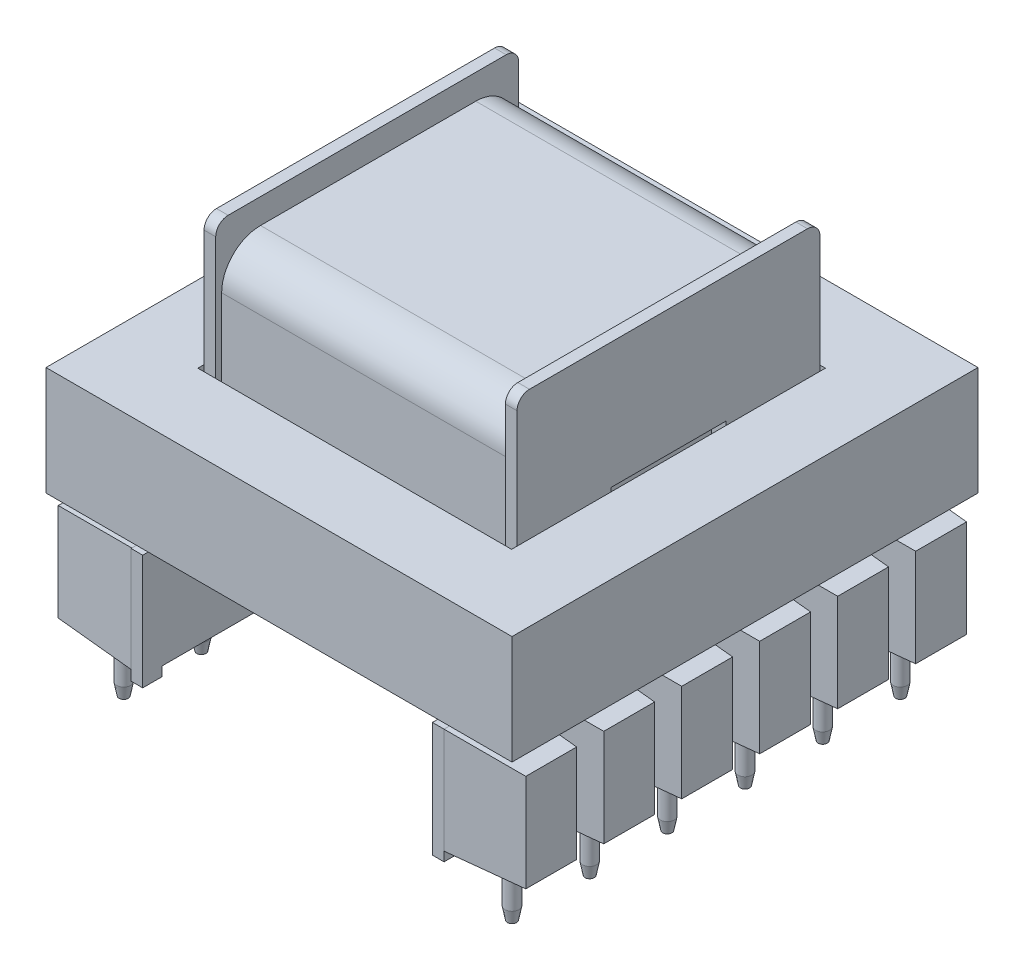
from build123d import *

# Parameters (mm, degrees)
BOSS_EXTRUDE1_DEPTH           = 11.8
BOSS_EXTRUDE1_DEPTH_BACK      = 11.8
SKETCH3_W                     = 18.65
SKETCH3_H                     = 7.4
CUT_EXTRUDE1_DEPTH            = 11.8
SKETCH4_W                     = 7.4
SKETCH4_H                     = 7.4
CUT_EXTRUDE2_DEPTH            = 25
FILLET1_R                     = 0.8
BOSS_EXTRUDE2_DEPTH           = 4.7
BOSS_EXTRUDE2_DEPTH_BACK      = 24.2
SKETCH5_W                     = 0.75
SKETCH5_H                     = 7.4
SKETCH6_W                     = 26.4
SKETCH6_H                     = 0.6
CUT_EXTRUDE3_DEPTH            = 25.3
SKETCH7_W                     = 3.8
SKETCH7_H                     = 6.8
BOSS_EXTRUDE3_DEPTH           = 5
BOSS_EXTRUDE3_DRAFT           = 3
BOSS_EXTRUDE3_PROFILE_2_DEPTH = 5
BOSS_EXTRUDE3_PROFILE_2_DRAFT = 3
BOSS_EXTRUDE3_PROFILE_3_DEPTH = 5
BOSS_EXTRUDE3_PROFILE_3_DRAFT = 3
BOSS_EXTRUDE3_PROFILE_4_DEPTH = 5
BOSS_EXTRUDE3_PROFILE_4_DRAFT = 3
BOSS_EXTRUDE3_PROFILE_5_DEPTH = 5
BOSS_EXTRUDE3_PROFILE_5_DRAFT = 3
BOSS_EXTRUDE3_PROFILE_6_DEPTH = 5
BOSS_EXTRUDE3_PROFILE_6_DRAFT = 3
SKETCH8_W                     = 3.8
SKETCH8_H                     = 6.8
BOSS_EXTRUDE4_DEPTH           = 5
BOSS_EXTRUDE4_DRAFT           = -3
BOSS_EXTRUDE4_PROFILE_2_DEPTH = 5
BOSS_EXTRUDE4_PROFILE_2_DRAFT = -3
BOSS_EXTRUDE4_PROFILE_3_DEPTH = 5
BOSS_EXTRUDE4_PROFILE_3_DRAFT = -3
BOSS_EXTRUDE4_PROFILE_4_DEPTH = 5
BOSS_EXTRUDE4_PROFILE_4_DRAFT = -3
BOSS_EXTRUDE4_PROFILE_5_DEPTH = 5
BOSS_EXTRUDE4_PROFILE_5_DRAFT = -3
BOSS_EXTRUDE4_PROFILE_6_DEPTH = 5
BOSS_EXTRUDE4_PROFILE_6_DRAFT = -3
SKETCH9_R                     = 0.45
BOSS_EXTRUDE5_DEPTH           = 4
BOSS_EXTRUDE5_OTHER_WAY_DEPTH = 0.8
BOSS_EXTRUDE5_OTHER_WAY_TAPER = 11
BOSS_EXTRUDE6_DEPTH           = 3.5
BOSS_EXTRUDE6_DEPTH_BACK      = 3.5
SKETCH12_W                    = 30
SKETCH12_H                    = 30
SKETCH12_W_2                  = 20.2
SKETCH12_H_2                  = 20.2
BOSS_EXTRUDE7_DEPTH           = 9.7
BOSS_EXTRUDE7_DEPTH_BACK      = 8.7
SKETCH13_W                    = 18.86
SKETCH13_H                    = 20.502794882
FILLET3_R                     = 2.5


with BuildPart() as part:
    # Sketch2 → Boss-Extrude1 (new, two sides: drawn at the far end of the back side and taken through both)
    with BuildSketch(Plane(origin=(0, 0, 0), x_dir=(1, 0, 0), z_dir=(0, 1, 0)).offset(-BOSS_EXTRUDE1_DEPTH_BACK)):
        Polygon((-9.514148802, 9.75), (-9.514148802, -9.75), (-8.764148802, -9.75), (-8.764148802, -4.35), (9.885851198, -4.35), (9.885851198, -9.75), (10.635851198, -9.75), (10.635851198, 9.75), (9.885851198, 9.75), (9.885851198, 4.35), (-8.764148802, 4.35), (-8.764148802, 9.75), align=None)
    extrude(amount=BOSS_EXTRUDE1_DEPTH + BOSS_EXTRUDE1_DEPTH_BACK)

    # Sketch3 → Cut-Extrude1 (cut)
    with BuildSketch(Plane.XY.offset(4.35)):
        with Locations((0.560851198, 8.1)):
            Rectangle(SKETCH3_W, SKETCH3_H)
        with Locations((0.560851198, -8.1)):
            Rectangle(SKETCH3_W, SKETCH3_H)
    extrude(amount=-CUT_EXTRUDE1_DEPTH, mode=Mode.SUBTRACT)

    # Sketch4 → Cut-Extrude2 (cut)
    with BuildSketch(Plane(origin=(10.635851198, 0, 0), x_dir=(0, 0, -1), z_dir=(1, 0, 0))):
        Rectangle(SKETCH4_W, SKETCH4_H)
    extrude(amount=-CUT_EXTRUDE2_DEPTH, mode=Mode.SUBTRACT)

    # Fillet1
    fillet1_edges = [part.edges().sort_by_distance(p)[0] for p in [
        (0.560851198, 4.4, -4.35),
        (0.560851198, -4.4, -4.35),
        (0.560851198, 4.4, 4.35),
        (0.560851198, -4.4, 4.35),
        (-9.139148802, 11.8, -9.75),
        (10.260851198, 11.8, -9.75),
        (-9.139148802, 11.8, 9.75),
        (10.260851198, 11.8, 9.75),
    ]]
    fillet(fillet1_edges, radius=FILLET1_R)

    # Sketch5 → Boss-Extrude2 (add, two sides: drawn at the far end of the back side and taken through both)
    with BuildSketch(Plane.XY.offset(9.75).offset(-BOSS_EXTRUDE2_DEPTH_BACK)):
        with Locations((10.260851198, -8.1)):
            Rectangle(SKETCH5_W, SKETCH5_H)
        with Locations((-9.139148802, -8.1)):
            Rectangle(SKETCH5_W, SKETCH5_H)
    extrude(amount=BOSS_EXTRUDE2_DEPTH + BOSS_EXTRUDE2_DEPTH_BACK)

    # Sketch6 → Cut-Extrude3 (cut)
    with BuildSketch(Plane.ZY.offset(9.514148802)):
        with Locations((0, -11.5)):
            Rectangle(SKETCH6_W, SKETCH6_H)
    extrude(amount=-CUT_EXTRUDE3_DEPTH, mode=Mode.SUBTRACT)


with BuildPart() as boss_extrude3_tool:
    # Sketch7 → Boss-Extrude3 (with draft: the straight prism first)
    with BuildSketch(Plane.ZY.offset(9.514148802)):
        with Locations((-12.5, -7.8)):
            Rectangle(SKETCH7_W, SKETCH7_H)
    extrude(amount=BOSS_EXTRUDE3_DEPTH)
    # Boss-Extrude3: the draft: its side faces are tilted about the plane it starts from
    boss_extrude3_sides = [boss_extrude3_tool.faces().sort_by_distance(p)[0] for p in [
        (-12.014148802, -4.4, -12.5),
        (-12.014148802, -7.8, -14.4),
        (-12.014148802, -11.2, -12.5),
        (-12.014148802, -7.8, -10.6),
    ]]
    draft(boss_extrude3_sides, Plane.ZY.offset(9.514148802), BOSS_EXTRUDE3_DRAFT)


with BuildPart() as part_1:
    add(part.part)

    # Boss-Extrude3: add boss_extrude3_tool
    add(boss_extrude3_tool.part)


with BuildPart() as boss_extrude3_profile_2_tool:
    # Sketch7 → Boss-Extrude3 profile 2 (with draft: the straight prism first)
    with BuildSketch(Plane.ZY.offset(9.514148802)):
        with Locations((-7.5, -7.8)):
            Rectangle(SKETCH7_W, SKETCH7_H)
    extrude(amount=BOSS_EXTRUDE3_PROFILE_2_DEPTH)
    # Boss-Extrude3 profile 2: the draft: its side faces are tilted about the plane it starts from
    boss_extrude3_profile_2_sides = [boss_extrude3_profile_2_tool.faces().sort_by_distance(p)[0] for p in [
        (-12.014148802, -7.8, -9.4),
        (-12.014148802, -11.2, -7.5),
        (-12.014148802, -7.8, -5.6),
        (-12.014148802, -4.4, -7.5),
    ]]
    draft(boss_extrude3_profile_2_sides, Plane.ZY.offset(9.514148802), BOSS_EXTRUDE3_PROFILE_2_DRAFT)


with BuildPart() as part_2:
    add(part_1.part)

    # Boss-Extrude3 profile 2: add boss_extrude3_profile_2_tool
    add(boss_extrude3_profile_2_tool.part)


with BuildPart() as boss_extrude3_profile_3_tool:
    # Sketch7 → Boss-Extrude3 profile 3 (with draft: the straight prism first)
    with BuildSketch(Plane.ZY.offset(9.514148802)):
        with Locations((-2.5, -7.8)):
            Rectangle(SKETCH7_W, SKETCH7_H)
    extrude(amount=BOSS_EXTRUDE3_PROFILE_3_DEPTH)
    # Boss-Extrude3 profile 3: the draft: its side faces are tilted about the plane it starts from
    boss_extrude3_profile_3_sides = [boss_extrude3_profile_3_tool.faces().sort_by_distance(p)[0] for p in [
        (-12.014148802, -7.8, -4.4),
        (-12.014148802, -11.2, -2.5),
        (-12.014148802, -7.8, -0.6),
        (-12.014148802, -4.4, -2.5),
    ]]
    draft(boss_extrude3_profile_3_sides, Plane.ZY.offset(9.514148802), BOSS_EXTRUDE3_PROFILE_3_DRAFT)


with BuildPart() as part_3:
    add(part_2.part)

    # Boss-Extrude3 profile 3: add boss_extrude3_profile_3_tool
    add(boss_extrude3_profile_3_tool.part)


with BuildPart() as boss_extrude3_profile_4_tool:
    # Sketch7 → Boss-Extrude3 profile 4 (with draft: the straight prism first)
    with BuildSketch(Plane.ZY.offset(9.514148802)):
        with Locations((2.5, -7.8)):
            Rectangle(SKETCH7_W, SKETCH7_H)
    extrude(amount=BOSS_EXTRUDE3_PROFILE_4_DEPTH)
    # Boss-Extrude3 profile 4: the draft: its side faces are tilted about the plane it starts from
    boss_extrude3_profile_4_sides = [boss_extrude3_profile_4_tool.faces().sort_by_distance(p)[0] for p in [
        (-12.014148802, -7.8, 0.6),
        (-12.014148802, -11.2, 2.5),
        (-12.014148802, -7.8, 4.4),
        (-12.014148802, -4.4, 2.5),
    ]]
    draft(boss_extrude3_profile_4_sides, Plane.ZY.offset(9.514148802), BOSS_EXTRUDE3_PROFILE_4_DRAFT)


with BuildPart() as part_4:
    add(part_3.part)

    # Boss-Extrude3 profile 4: add boss_extrude3_profile_4_tool
    add(boss_extrude3_profile_4_tool.part)


with BuildPart() as boss_extrude3_profile_5_tool:
    # Sketch7 → Boss-Extrude3 profile 5 (with draft: the straight prism first)
    with BuildSketch(Plane.ZY.offset(9.514148802)):
        with Locations((7.5, -7.8)):
            Rectangle(SKETCH7_W, SKETCH7_H)
    extrude(amount=BOSS_EXTRUDE3_PROFILE_5_DEPTH)
    # Boss-Extrude3 profile 5: the draft: its side faces are tilted about the plane it starts from
    boss_extrude3_profile_5_sides = [boss_extrude3_profile_5_tool.faces().sort_by_distance(p)[0] for p in [
        (-12.014148802, -7.8, 5.6),
        (-12.014148802, -11.2, 7.5),
        (-12.014148802, -7.8, 9.4),
        (-12.014148802, -4.4, 7.5),
    ]]
    draft(boss_extrude3_profile_5_sides, Plane.ZY.offset(9.514148802), BOSS_EXTRUDE3_PROFILE_5_DRAFT)


with BuildPart() as part_5:
    add(part_4.part)

    # Boss-Extrude3 profile 5: add boss_extrude3_profile_5_tool
    add(boss_extrude3_profile_5_tool.part)


with BuildPart() as boss_extrude3_profile_6_tool:
    # Sketch7 → Boss-Extrude3 profile 6 (with draft: the straight prism first)
    with BuildSketch(Plane.ZY.offset(9.514148802)):
        with Locations((12.5, -7.8)):
            Rectangle(SKETCH7_W, SKETCH7_H)
    extrude(amount=BOSS_EXTRUDE3_PROFILE_6_DEPTH)
    # Boss-Extrude3 profile 6: the draft: its side faces are tilted about the plane it starts from
    boss_extrude3_profile_6_sides = [boss_extrude3_profile_6_tool.faces().sort_by_distance(p)[0] for p in [
        (-12.014148802, -7.8, 10.6),
        (-12.014148802, -11.2, 12.5),
        (-12.014148802, -7.8, 14.4),
        (-12.014148802, -4.4, 12.5),
    ]]
    draft(boss_extrude3_profile_6_sides, Plane.ZY.offset(9.514148802), BOSS_EXTRUDE3_PROFILE_6_DRAFT)


with BuildPart() as part_6:
    add(part_5.part)

    # Boss-Extrude3 profile 6: add boss_extrude3_profile_6_tool
    add(boss_extrude3_profile_6_tool.part)


with BuildPart() as boss_extrude4_tool:
    # Sketch8 → Boss-Extrude4 (with draft: the straight prism first)
    with BuildSketch(Plane(origin=(10.635851198, 0, -10.635851198), x_dir=(0, 0, 1), z_dir=(-1, 0, 0))):
        with Locations((-1.914148802, -7.8)):
            Rectangle(SKETCH8_W, SKETCH8_H)
    extrude(amount=-BOSS_EXTRUDE4_DEPTH)
    # Boss-Extrude4: the draft: its side faces are tilted about the plane it starts from
    boss_extrude4_sides = [boss_extrude4_tool.faces().sort_by_distance(p)[0] for p in [
        (13.135851198, -7.8, -14.45),
        (13.135851198, -11.2, -12.55),
        (13.135851198, -7.8, -10.65),
        (13.135851198, -4.4, -12.55),
    ]]
    draft(boss_extrude4_sides, Plane(origin=(10.635851198, 0, -10.635851198), x_dir=(0, 0, 1), z_dir=(-1, 0, 0)), BOSS_EXTRUDE4_DRAFT)


with BuildPart() as part_7:
    add(part_6.part)

    # Boss-Extrude4: add boss_extrude4_tool
    add(boss_extrude4_tool.part)


with BuildPart() as boss_extrude4_profile_2_tool:
    # Sketch8 → Boss-Extrude4 profile 2 (with draft: the straight prism first)
    with BuildSketch(Plane(origin=(10.635851198, 0, -10.635851198), x_dir=(0, 0, 1), z_dir=(-1, 0, 0))):
        with Locations((3.105851198, -7.8)):
            Rectangle(SKETCH8_W, SKETCH8_H)
    extrude(amount=-BOSS_EXTRUDE4_PROFILE_2_DEPTH)
    # Boss-Extrude4 profile 2: the draft: its side faces are tilted about the plane it starts from
    boss_extrude4_profile_2_sides = [boss_extrude4_profile_2_tool.faces().sort_by_distance(p)[0] for p in [
        (13.135851198, -7.8, -9.43),
        (13.135851198, -11.2, -7.53),
        (13.135851198, -7.8, -5.63),
        (13.135851198, -4.4, -7.53),
    ]]
    draft(boss_extrude4_profile_2_sides, Plane(origin=(10.635851198, 0, -10.635851198), x_dir=(0, 0, 1), z_dir=(-1, 0, 0)), BOSS_EXTRUDE4_PROFILE_2_DRAFT)


with BuildPart() as part_8:
    add(part_7.part)

    # Boss-Extrude4 profile 2: add boss_extrude4_profile_2_tool
    add(boss_extrude4_profile_2_tool.part)


with BuildPart() as boss_extrude4_profile_3_tool:
    # Sketch8 → Boss-Extrude4 profile 3 (with draft: the straight prism first)
    with BuildSketch(Plane(origin=(10.635851198, 0, -10.635851198), x_dir=(0, 0, 1), z_dir=(-1, 0, 0))):
        with Locations((8.125851198, -7.8)):
            Rectangle(SKETCH8_W, SKETCH8_H)
    extrude(amount=-BOSS_EXTRUDE4_PROFILE_3_DEPTH)
    # Boss-Extrude4 profile 3: the draft: its side faces are tilted about the plane it starts from
    boss_extrude4_profile_3_sides = [boss_extrude4_profile_3_tool.faces().sort_by_distance(p)[0] for p in [
        (13.135851198, -7.8, -4.41),
        (13.135851198, -11.2, -2.51),
        (13.135851198, -7.8, -0.61),
        (13.135851198, -4.4, -2.51),
    ]]
    draft(boss_extrude4_profile_3_sides, Plane(origin=(10.635851198, 0, -10.635851198), x_dir=(0, 0, 1), z_dir=(-1, 0, 0)), BOSS_EXTRUDE4_PROFILE_3_DRAFT)


with BuildPart() as part_9:
    add(part_8.part)

    # Boss-Extrude4 profile 3: add boss_extrude4_profile_3_tool
    add(boss_extrude4_profile_3_tool.part)


with BuildPart() as boss_extrude4_profile_4_tool:
    # Sketch8 → Boss-Extrude4 profile 4 (with draft: the straight prism first)
    with BuildSketch(Plane(origin=(10.635851198, 0, -10.635851198), x_dir=(0, 0, 1), z_dir=(-1, 0, 0))):
        with Locations((13.145851198, -7.8)):
            Rectangle(SKETCH8_W, SKETCH8_H)
    extrude(amount=-BOSS_EXTRUDE4_PROFILE_4_DEPTH)
    # Boss-Extrude4 profile 4: the draft: its side faces are tilted about the plane it starts from
    boss_extrude4_profile_4_sides = [boss_extrude4_profile_4_tool.faces().sort_by_distance(p)[0] for p in [
        (13.135851198, -7.8, 0.61),
        (13.135851198, -11.2, 2.51),
        (13.135851198, -7.8, 4.41),
        (13.135851198, -4.4, 2.51),
    ]]
    draft(boss_extrude4_profile_4_sides, Plane(origin=(10.635851198, 0, -10.635851198), x_dir=(0, 0, 1), z_dir=(-1, 0, 0)), BOSS_EXTRUDE4_PROFILE_4_DRAFT)


with BuildPart() as part_10:
    add(part_9.part)

    # Boss-Extrude4 profile 4: add boss_extrude4_profile_4_tool
    add(boss_extrude4_profile_4_tool.part)


with BuildPart() as boss_extrude4_profile_5_tool:
    # Sketch8 → Boss-Extrude4 profile 5 (with draft: the straight prism first)
    with BuildSketch(Plane(origin=(10.635851198, 0, -10.635851198), x_dir=(0, 0, 1), z_dir=(-1, 0, 0))):
        with Locations((18.165851198, -7.8)):
            Rectangle(SKETCH8_W, SKETCH8_H)
    extrude(amount=-BOSS_EXTRUDE4_PROFILE_5_DEPTH)
    # Boss-Extrude4 profile 5: the draft: its side faces are tilted about the plane it starts from
    boss_extrude4_profile_5_sides = [boss_extrude4_profile_5_tool.faces().sort_by_distance(p)[0] for p in [
        (13.135851198, -7.8, 5.63),
        (13.135851198, -11.2, 7.53),
        (13.135851198, -7.8, 9.43),
        (13.135851198, -4.4, 7.53),
    ]]
    draft(boss_extrude4_profile_5_sides, Plane(origin=(10.635851198, 0, -10.635851198), x_dir=(0, 0, 1), z_dir=(-1, 0, 0)), BOSS_EXTRUDE4_PROFILE_5_DRAFT)


with BuildPart() as part_11:
    add(part_10.part)

    # Boss-Extrude4 profile 5: add boss_extrude4_profile_5_tool
    add(boss_extrude4_profile_5_tool.part)


with BuildPart() as boss_extrude4_profile_6_tool:
    # Sketch8 → Boss-Extrude4 profile 6 (with draft: the straight prism first)
    with BuildSketch(Plane(origin=(10.635851198, 0, -10.635851198), x_dir=(0, 0, 1), z_dir=(-1, 0, 0))):
        with Locations((23.185851198, -7.8)):
            Rectangle(SKETCH8_W, SKETCH8_H)
    extrude(amount=-BOSS_EXTRUDE4_PROFILE_6_DEPTH)
    # Boss-Extrude4 profile 6: the draft: its side faces are tilted about the plane it starts from
    boss_extrude4_profile_6_sides = [boss_extrude4_profile_6_tool.faces().sort_by_distance(p)[0] for p in [
        (13.135851198, -4.4, 12.55),
        (13.135851198, -7.8, 10.65),
        (13.135851198, -11.2, 12.55),
        (13.135851198, -7.8, 14.45),
    ]]
    draft(boss_extrude4_profile_6_sides, Plane(origin=(10.635851198, 0, -10.635851198), x_dir=(0, 0, 1), z_dir=(-1, 0, 0)), BOSS_EXTRUDE4_PROFILE_6_DRAFT)


with BuildPart() as part_12:
    add(part_11.part)

    # Boss-Extrude4 profile 6: add boss_extrude4_profile_6_tool
    add(boss_extrude4_profile_6_tool.part)

    # Sketch9 → Boss-Extrude5 (add)
    with BuildSketch(Plane(origin=(0, -14, 0), x_dir=(1, 0, 0), z_dir=(0, 1, 0))):
        with Locations((-11.939148802, 12.5)):
            Circle(SKETCH9_R)
        with Locations((-11.939148802, 7.5)):
            Circle(SKETCH9_R)
        with Locations((-11.939148802, 2.5)):
            Circle(SKETCH9_R)
        with Locations((-11.939148802, -2.5)):
            Circle(SKETCH9_R)
        with Locations((-11.939148802, -7.5)):
            Circle(SKETCH9_R)
        with Locations((-11.939148802, -12.5)):
            Circle(SKETCH9_R)
        with Locations((13.060851198, -12.5)):
            Circle(SKETCH9_R)
        with Locations((13.060851198, -7.5)):
            Circle(SKETCH9_R)
        with Locations((13.060851198, -2.5)):
            Circle(SKETCH9_R)
        with Locations((13.060851198, 2.5)):
            Circle(SKETCH9_R)
        with Locations((13.060851198, 7.5)):
            Circle(SKETCH9_R)
        with Locations((13.060851198, 12.5)):
            Circle(SKETCH9_R)
    extrude(amount=BOSS_EXTRUDE5_DEPTH)

    # Sketch9 → Boss-Extrude5 other way (add)
    with BuildSketch(Plane(origin=(0, -14, 0), x_dir=(1, 0, 0), z_dir=(0, 1, 0))):
        with Locations((-11.939148802, 12.5)):
            Circle(SKETCH9_R)
        with Locations((-11.939148802, 7.5)):
            Circle(SKETCH9_R)
        with Locations((-11.939148802, 2.5)):
            Circle(SKETCH9_R)
        with Locations((-11.939148802, -2.5)):
            Circle(SKETCH9_R)
        with Locations((-11.939148802, -7.5)):
            Circle(SKETCH9_R)
        with Locations((-11.939148802, -12.5)):
            Circle(SKETCH9_R)
        with Locations((13.060851198, -12.5)):
            Circle(SKETCH9_R)
        with Locations((13.060851198, -7.5)):
            Circle(SKETCH9_R)
        with Locations((13.060851198, -2.5)):
            Circle(SKETCH9_R)
        with Locations((13.060851198, 2.5)):
            Circle(SKETCH9_R)
        with Locations((13.060851198, 7.5)):
            Circle(SKETCH9_R)
        with Locations((13.060851198, 12.5)):
            Circle(SKETCH9_R)
    extrude(amount=-BOSS_EXTRUDE5_OTHER_WAY_DEPTH, taper=BOSS_EXTRUDE5_OTHER_WAY_TAPER)

    # Sketch12 → Boss-Extrude6 (add, two sides: drawn at the far end of the back side and taken through both)
    with BuildSketch(Plane(origin=(0, 0, 0), x_dir=(1, 0, 0), z_dir=(0, 1, 0)).offset(-BOSS_EXTRUDE6_DEPTH_BACK)):
        with Locations((0.560851198, 0)):
            Rectangle(SKETCH12_W, SKETCH12_H)
        with Locations((0.585851198, -0.05)):
            Rectangle(SKETCH12_W_2, SKETCH12_H_2, mode=Mode.SUBTRACT)
    extrude(amount=BOSS_EXTRUDE6_DEPTH + BOSS_EXTRUDE6_DEPTH_BACK)

    # Sketch13 → Boss-Extrude7 (add, two sides: drawn at the far end of the back side and taken through both)
    with BuildSketch(Plane(origin=(0, 0, 0), x_dir=(0, 0, -1), z_dir=(1, 0, 0)).offset(-BOSS_EXTRUDE7_DEPTH_BACK)):
        Rectangle(SKETCH13_W, SKETCH13_H)
    extrude(amount=BOSS_EXTRUDE7_DEPTH + BOSS_EXTRUDE7_DEPTH_BACK)

    # Fillet3
    fillet3_edges = [part_12.edges().sort_by_distance(p)[0] for p in [
        (0.5, -10.251397441, -9.43),
        (0.5, -10.251397441, 9.43),
        (0.5, 10.251397441, -9.43),
        (0.5, 10.251397441, 9.43),
    ]]
    fillet(fillet3_edges, radius=FILLET3_R)


solid = part_12.part
